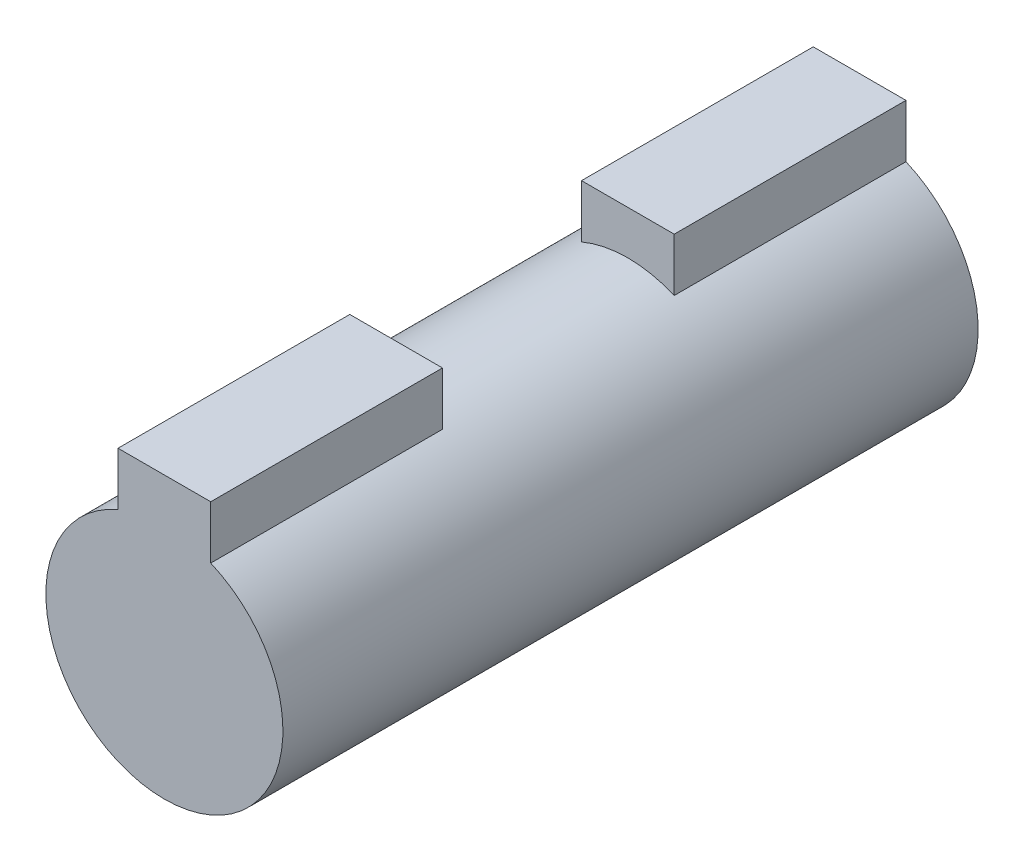
from build123d import *

# Parameters (mm, degrees)
BOSS_EXTRUDE1_DEPTH = 30
CUT_EXTRUDE2_START  = -10
SKETCH2_R           = 9.068137576
SKETCH2_R_2         = 5.1145
CUT_EXTRUDE2_DEPTH  = 10


with BuildPart() as part:
    # Sketch1 → Boss-Extrude1 (new body)
    with BuildSketch(Plane.XY):
        with BuildLine():
            Line((-2, 7), (2, 7))
            Line((2, 7), (2, 4.707240195))
            ThreePointArc((2, 4.707240195), (0, -5.1145), (-2, 4.707240195))
            Line((-2, 4.707240195), (-2, 7))
        make_face()
    extrude(amount=BOSS_EXTRUDE1_DEPTH)

    # Sketch2 → Cut-Extrude2 (cut)
    with BuildSketch(Plane.XY.offset(30).offset(CUT_EXTRUDE2_START)):
        Circle(SKETCH2_R)
        Circle(SKETCH2_R_2, mode=Mode.SUBTRACT)
    extrude(amount=-CUT_EXTRUDE2_DEPTH, mode=Mode.SUBTRACT)


solid = part.part
